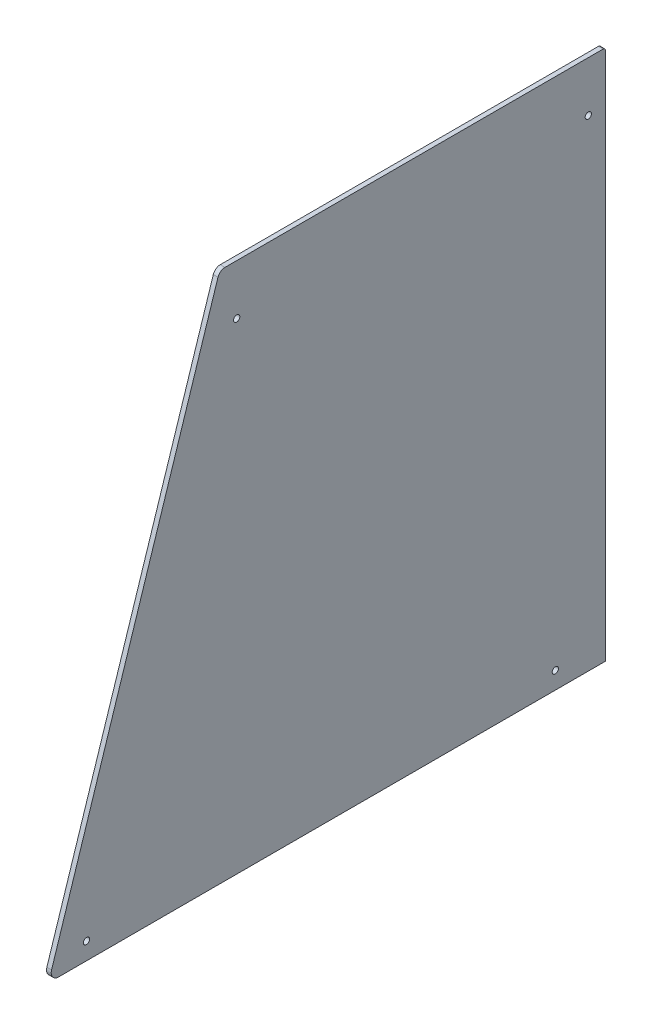
from build123d import *

# Parameters (mm, degrees)
BOSS_EXTRUDE1_DEPTH = 3
CUT_EXTRUDE2_REACH  = 5
SKETCH2_R           = 2


with BuildPart() as part:
    # Sketch1 → Boss-Extrude1 (new body)
    with BuildSketch(Plane(origin=(110.5, 0, 0), x_dir=(0, 0, -1), z_dir=(1, 0, 0))):
        with BuildLine():
            Line((122.5, 328.5), (122.5, -10))
            Line((122.5, -10), (-227.5, -10))
            ThreePointArc((-227.5, -10), (-231.293387843, -8.070194473), (-231.967157887, -3.867817213))
            Line((-231.967157887, -3.867817213), (-125.468557887, 326.745775479))
            ThreePointArc((-125.468557887, 326.745775479), (-123.764798126, 329.10018419), (-121.0014, 330))
            Line((-121.0014, 330), (121, 330))
            ThreePointArc((121, 330), (122.060660172, 329.560660172), (122.5, 328.5))
        make_face()
    extrude(amount=-BOSS_EXTRUDE1_DEPTH)

    # Sketch2 → Cut-Extrude2 (cut, up to next)
    with BuildSketch(Plane(origin=(110.5, 0, 0), x_dir=(0, 0, -1), z_dir=(1, 0, 0)), mode=Mode.PRIVATE) as cut_extrude2_sk1:
        with Locations((111.5014, 297.910969137)):
            Circle(SKETCH2_R)
    cut_extrude2_tool1 = extrude(cut_extrude2_sk1.sketch, amount=-CUT_EXTRUDE2_REACH, mode=Mode.PRIVATE) & part.part
    add(cut_extrude2_tool1.solids().sort_by_distance((110.5, 297.910969, -111.5014))[0], mode=Mode.SUBTRACT)
    # Sketch2 → Cut-Extrude2 (cut, up to next)
    with BuildSketch(Plane(origin=(110.5, 0, 0), x_dir=(0, 0, -1), z_dir=(1, 0, 0)), mode=Mode.PRIVATE) as cut_extrude2_sk2:
        with Locations((90.410969137, 0.9986)):
            Circle(SKETCH2_R)
    cut_extrude2_tool2 = extrude(cut_extrude2_sk2.sketch, amount=-CUT_EXTRUDE2_REACH, mode=Mode.PRIVATE) & part.part
    add(cut_extrude2_tool2.solids().sort_by_distance((110.5, 0.9986, -90.410969))[0], mode=Mode.SUBTRACT)
    # Sketch2 → Cut-Extrude2 (cut, up to next)
    with BuildSketch(Plane(origin=(110.5, 0, 0), x_dir=(0, 0, -1), z_dir=(1, 0, 0)), mode=Mode.PRIVATE) as cut_extrude2_sk3:
        with Locations((-209.589030863, 0.9986)):
            Circle(SKETCH2_R)
    cut_extrude2_tool3 = extrude(cut_extrude2_sk3.sketch, amount=-CUT_EXTRUDE2_REACH, mode=Mode.PRIVATE) & part.part
    add(cut_extrude2_tool3.solids().sort_by_distance((110.5, 0.9986, 209.589031))[0], mode=Mode.SUBTRACT)
    # Sketch2 → Cut-Extrude2 (cut, up to next)
    with BuildSketch(Plane(origin=(110.5, 0, 0), x_dir=(0, 0, -1), z_dir=(1, 0, 0)), mode=Mode.PRIVATE) as cut_extrude2_sk4:
        with Locations((-113.4986, 297.910969137)):
            Circle(SKETCH2_R)
    cut_extrude2_tool4 = extrude(cut_extrude2_sk4.sketch, amount=-CUT_EXTRUDE2_REACH, mode=Mode.PRIVATE) & part.part
    add(cut_extrude2_tool4.solids().sort_by_distance((110.5, 297.910969, 113.4986))[0], mode=Mode.SUBTRACT)


solid = part.part
